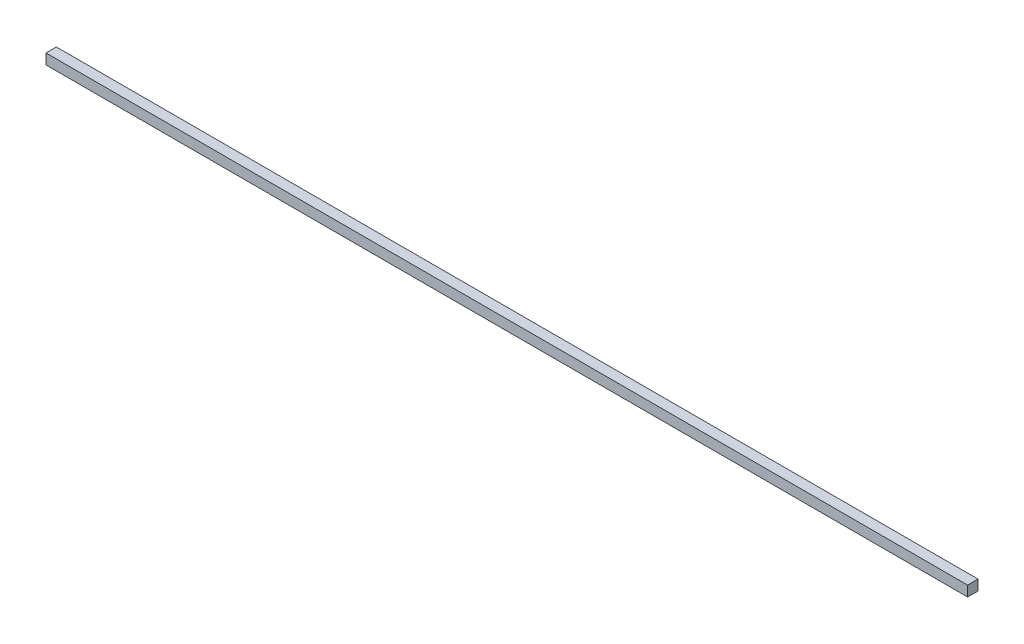
from build123d import *

# Parameters (mm, degrees)
SKETCH1_W           = 888.53
SKETCH1_H           = 10
BOSS_EXTRUDE1_DEPTH = 10


with BuildPart() as part:
    # Sketch1 → Boss-Extrude1 (new body)
    with BuildSketch(Plane(origin=(0, 0, 0), x_dir=(1, 0, 0), z_dir=(0, 1, 0))):
        Rectangle(SKETCH1_W, SKETCH1_H)
    extrude(amount=BOSS_EXTRUDE1_DEPTH)


solid = part.part
